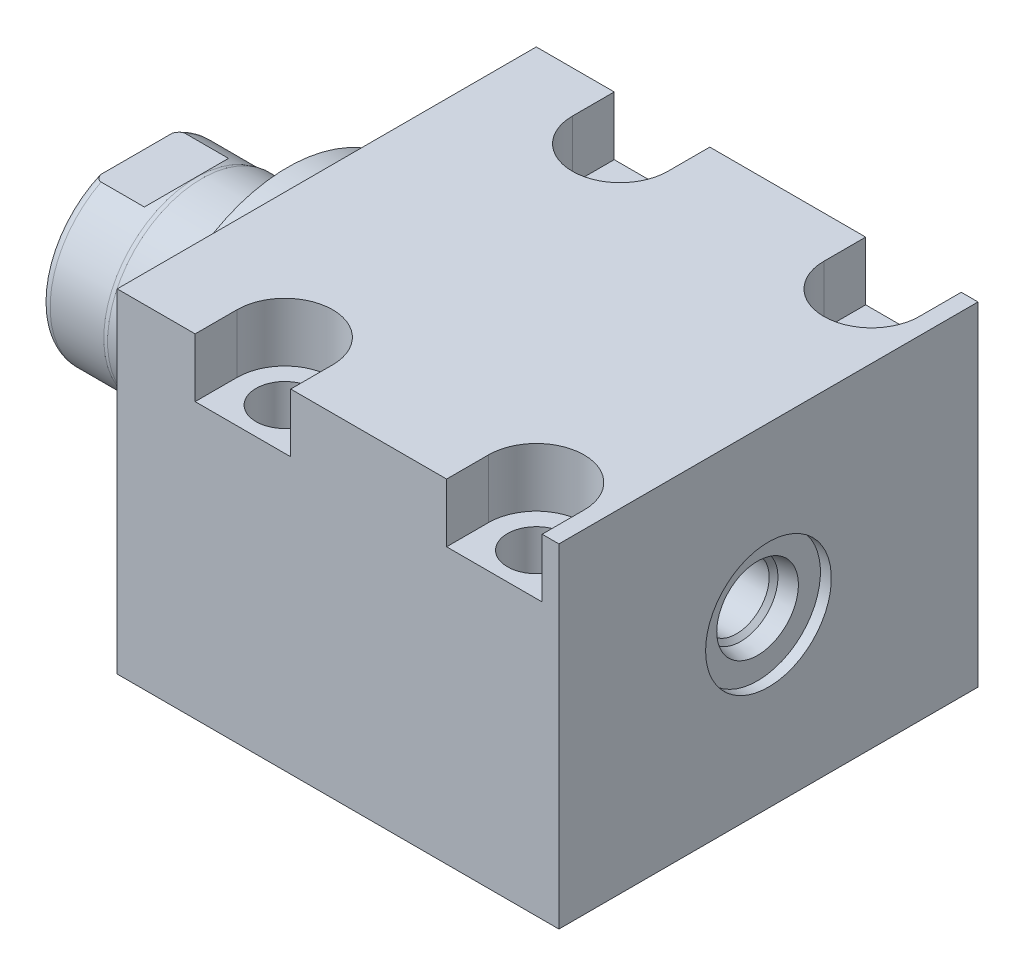
from build123d import *

# Parameters (mm, degrees)
SKETCH1_W          = 63.5
SKETCH1_H          = 50.546
EXTRUDE1_DEPTH     = 66.929
SKETCH5_R          = 22.225
EXTRUDE2_DEPTH     = 5.969
SKETCH6_W          = 14.2875
SKETCH6_H          = 22.86
CUT_EXTRUDE4_DEPTH = 30.48
HOLE2_D            = 8.7376
HOLE2_DEPTH        = 50.546
LPATTERN1_COUNT    = 2
LPATTERN1_PITCH    = 38.1
CUT_EXTRUDE5_DEPTH = 8.89
HOLE3_D            = 3.175
HOLE3_DEPTH        = 9.525
HOLE3_CBORE_D      = 11.3411
HOLE3_CBORE_DEPTH  = 1.4478
HOLE3_TIP          = 0.953866233
HOLE4_D            = 3.175
HOLE4_DEPTH        = 9.525
HOLE4_CBORE_D      = 11.3411
HOLE4_CBORE_DEPTH  = 1.4478
HOLE4_TIP          = 0.953866233
CHAMFER1_SIZE      = 0.635
SKETCH23_R         = 1.4478
LPATTERN3_COUNT    = 2
LPATTERN3_PITCH    = 38.1


with BuildPart() as part:
    # Sketch1 → Extrude1 (new body)
    with BuildSketch(Plane(origin=(0, 0, 0), x_dir=(0, 0, -1), z_dir=(1, 0, 0))):
        with Locations((0, -0.127)):
            Rectangle(SKETCH1_W, SKETCH1_H)
    extrude(amount=EXTRUDE1_DEPTH)

    # Sketch5 → Extrude2 (add)
    with BuildSketch(Plane.ZY):
        with Locations(Location((0, 0, 0), (0, 0, 180))):  # turned: the seam where the file's is
            Circle(SKETCH5_R)
    extrude(amount=EXTRUDE2_DEPTH)

    # Sketch6 → Revolve1 (revolve)
    with BuildSketch(Plane(origin=(0, 0, 0), x_dir=(0, 0, 1), z_dir=(0, -1, 0))):
        with Locations((-7.14375, 17.399)):
            Rectangle(SKETCH6_W, SKETCH6_H)
    revolve(axis=Axis((5.754582971, 0, 0), (-1, 0, 0)))

    # S2D0001 → Cut-Revolve4 (revolve, cut)
    with BuildSketch(Plane(origin=(-18.511260017, 3.2639, 0), x_dir=(0, 1, 0), z_dir=(0, 0, 1)), mode=Mode.PRIVATE) as cut_revolve4_sk:
        Polygon((2.286, 8.250017728), (2.286, -6.522460017), (-3.2639, -6.522460017), (-3.2639, 10.317739983), (3.4798, 10.317739983), align=None)
    revolve(cut_revolve4_sk.sketch.rotate(Axis((0, 0, 0), (-1, 0, 0)), 90), axis=Axis((0, 0, 0), (-1, 0, 0)), mode=Mode.SUBTRACT)  # turned: the seam where the file's is

    # Sketch8 → Cut-Revolve5 (revolve, cut)
    with BuildSketch(Plane(origin=(0, 0, 0), x_dir=(0, 0, -1), z_dir=(0, 1, 0)), mode=Mode.PRIVATE) as cut_revolve5_sk:
        with BuildLine():
            Line((-14.2875, 18.923), (-14.097, 19.685))
            Line((-14.097, 19.685), (-14.097, 27.813))
            ThreePointArc((-14.097, 27.813), (-13.996678675, 28.356796865), (-13.708922533, 28.829))
            Line((-13.708922533, 28.829), (-14.2875, 28.829))
            Line((-14.2875, 28.829), (-14.2875, 18.923))
        make_face()
    revolve(cut_revolve5_sk.sketch.rotate(Axis((-12.65936, 0, 0), (-1, 0, 0)), 180), axis=Axis((-12.65936, 0, 0), (-1, 0, 0)), mode=Mode.SUBTRACT)  # turned: the seam where the file's is

    # Sketch12 → Cut-Extrude4 (cut, symmetric)
    with BuildSketch(Plane(origin=(0, 0, 0), x_dir=(0, -1, 0), z_dir=(0, 0, -1))):
        Polygon((12.573, 28.829), (12.573, 21.2598), (14.097, 19.7358), (14.097, 28.829), align=None)
        Polygon((-12.573, 28.829), (-12.573, 21.2598), (-14.097, 19.7358), (-14.097, 28.829), align=None)
    extrude(amount=CUT_EXTRUDE4_DEPTH, both=True, mode=Mode.SUBTRACT)

    # Hole2
    with Locations(Plane(origin=(0, 25.146, 0), x_dir=(-1, 0, 0), z_dir=(0, 1, 0))):
        with Locations((-19.05, -25.4), (-19.05, 25.4)):
            hole2 = Hole(HOLE2_D / 2, depth=HOLE2_DEPTH)

    # LPattern1: Hole2 ×2
    with Locations(*[(i * LPATTERN1_PITCH, 0, 0) for i in range(1, LPATTERN1_COUNT)]):
        add(hole2, mode=Mode.SUBTRACT)

    # Sketch18 → Cut-Extrude5 (cut)
    with BuildSketch(Plane(origin=(0, 25.146, 0), x_dir=(1, 0, 0), z_dir=(0, 1, 0))):
        with BuildLine():
            Line((64.389, -31.75), (49.911, -31.75))
            Line((49.911, -31.75), (49.911, -25.4))
            ThreePointArc((49.911, -25.4), (57.15, -18.161), (64.389, -25.4))
            Line((64.389, -25.4), (64.389, -31.75))
        make_face()
        with BuildLine():
            Line((11.811, -25.4), (11.811, -31.75))
            Line((11.811, -31.75), (26.289, -31.75))
            Line((26.289, -31.75), (26.289, -25.4))
            ThreePointArc((26.289, -25.4), (19.05, -18.161), (11.811, -25.4))
        make_face()
        with BuildLine():
            Line((64.389, 25.4), (64.389, 31.75))
            Line((64.389, 31.75), (49.911, 31.75))
            Line((49.911, 31.75), (49.911, 25.4))
            ThreePointArc((49.911, 25.4), (57.15, 18.161), (64.389, 25.4))
        make_face()
        with BuildLine():
            Line((26.289, 31.75), (11.811, 31.75))
            Line((11.811, 31.75), (11.811, 25.4))
            ThreePointArc((11.811, 25.4), (19.05, 18.161), (26.289, 25.4))
            Line((26.289, 25.4), (26.289, 31.75))
        make_face()
    extrude(amount=-CUT_EXTRUDE5_DEPTH, mode=Mode.SUBTRACT)

    # Hole3
    with Locations(Plane.XZ.offset(25.4)):
        with Locations((12.7, 0)):
            CounterBoreHole(HOLE3_D / 2, HOLE3_CBORE_D / 2, HOLE3_CBORE_DEPTH, depth=HOLE3_DEPTH)
            with Locations((0, 0, -(HOLE3_DEPTH + HOLE3_TIP / 2))):  # 118° drill point
                Cone(0, HOLE3_D / 2, HOLE3_TIP, mode=Mode.SUBTRACT)

    # Hole4
    with Locations(Plane.XZ.offset(25.4)):
        with Locations((50.8, 0)):
            CounterBoreHole(HOLE4_D / 2, HOLE4_CBORE_D / 2, HOLE4_CBORE_DEPTH, depth=HOLE4_DEPTH)
            with Locations((0, 0, -(HOLE4_DEPTH + HOLE4_TIP / 2))):  # 118° drill point
                Cone(0, HOLE4_D / 2, HOLE4_TIP, mode=Mode.SUBTRACT)

    # Chamfer1
    chamfer1_edges = [part.edges().sort_by_distance(p)[0] for p in [
        (14.2875, -23.9522, 0),
        (52.3875, -23.9522, 0),
    ]]
    chamfer(chamfer1_edges, length=CHAMFER1_SIZE)

    # Sketch24 → Cut-Revolve6 (revolve, cut)
    with BuildSketch(Plane.XY, mode=Mode.PRIVATE) as cut_revolve6_sk:
        Polygon((66.929, 9.525), (65.278, 9.525), (65.278, 6.1849), (62.7253, 5.642306865), (62.061393135, 4.9784), (50.673, 4.9784), (50.673, 0), (66.929, 0), align=None)
    revolve(cut_revolve6_sk.sketch.rotate(Axis((0, 0, 0), (1, 0, 0)), 270), axis=Axis((0, 0, 0), (1, 0, 0)), mode=Mode.SUBTRACT)  # turned: the seam where the file's is


with BuildPart() as body_2:
    # Sketch23 → Revolve2 (revolve)
    with BuildSketch(Plane.XY, mode=Mode.PRIVATE) as revolve2_sk:
        with Locations((8.47725, -25.4)):
            Circle(SKETCH23_R)
    revolve(revolve2_sk.sketch.rotate(Axis((12.7, -23.9522, 0), (0, 1, 0)), 270), axis=Axis((12.7, -23.9522, 0), (0, 1, 0)))  # turned: the seam where the file's is


with BuildPart() as lpattern3_1:
    # LPattern3: pattern copy
    add(body_2.part.moved(Location(Vector(1, 0, 0) * (1 * LPATTERN3_PITCH))))


solid = Compound([part.part, body_2.part, lpattern3_1.part])
